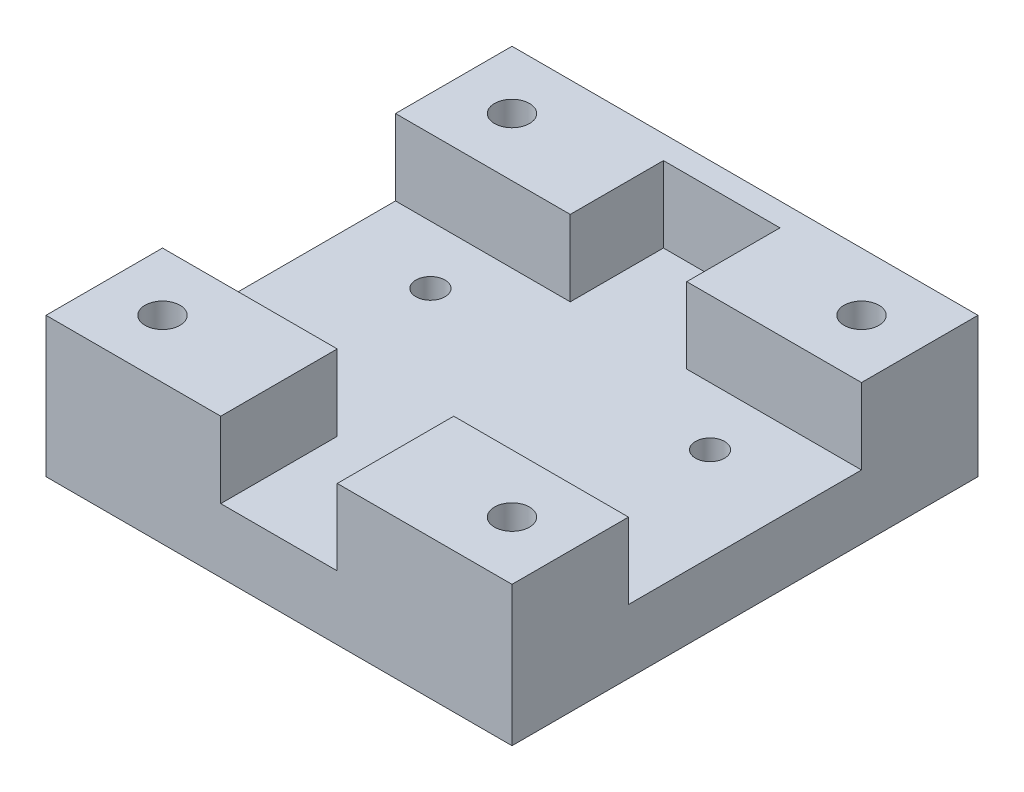
from build123d import *

# Parameters (mm, degrees)
BOSS_EXTRU_1_DEPTH      = 40
ENL_V_MAT_EXTRU_1_REACH = 14
ESQUISSE2_R             = 1.5
ESQUISSE2_R_2           = 1.25
ESQUISSE3_W             = 15
ESQUISSE3_H             = 20
ENL_V_MAT_EXTRU_2_DEPTH = 6.5
ESQUISSE4_W             = 40
ESQUISSE4_H             = 12
BOSS_EXTRU_2_DEPTH      = 2
CHANFREIN1_SIZE         = 2


with BuildPart() as part:
    # Esquisse1 → Boss.-Extru.1 (new body)
    with BuildSketch(Plane.XY):
        Polygon((5, 0), (20, 0), (20, -12), (-20, -12), (-20, 0), (-5, 0), (-5, -6.5), (5, -6.5), align=None)
    extrude(amount=BOSS_EXTRU_1_DEPTH)

    # Esquisse2 → Enlèv. mat.-Extru.1 (cut, up to next)
    with BuildSketch(Plane(origin=(0, 0, 0), x_dir=(1, 0, 0), z_dir=(0, 1, 0)), mode=Mode.PRIVATE) as enl_v_mat_extru_1_sk1:
        with Locations((-15, -5)):
            Circle(ESQUISSE2_R)
    enl_v_mat_extru_1_tool1 = extrude(enl_v_mat_extru_1_sk1.sketch, amount=-ENL_V_MAT_EXTRU_1_REACH, mode=Mode.PRIVATE) & part.part
    add(enl_v_mat_extru_1_tool1.solids().sort_by_distance((-15, 0, 5))[0], mode=Mode.SUBTRACT)
    # Esquisse2 → Enlèv. mat.-Extru.1 (cut, up to next)
    with BuildSketch(Plane(origin=(0, 0, 0), x_dir=(1, 0, 0), z_dir=(0, 1, 0)), mode=Mode.PRIVATE) as enl_v_mat_extru_1_sk2:
        with Locations((-15, -35)):
            Circle(ESQUISSE2_R)
    enl_v_mat_extru_1_tool2 = extrude(enl_v_mat_extru_1_sk2.sketch, amount=-ENL_V_MAT_EXTRU_1_REACH, mode=Mode.PRIVATE) & part.part
    add(enl_v_mat_extru_1_tool2.solids().sort_by_distance((-15, 0, 35))[0], mode=Mode.SUBTRACT)
    # Esquisse2 → Enlèv. mat.-Extru.1 (cut, up to next)
    with BuildSketch(Plane(origin=(0, 0, 0), x_dir=(1, 0, 0), z_dir=(0, 1, 0)), mode=Mode.PRIVATE) as enl_v_mat_extru_1_sk3:
        with Locations((15, -35)):
            Circle(ESQUISSE2_R)
    enl_v_mat_extru_1_tool3 = extrude(enl_v_mat_extru_1_sk3.sketch, amount=-ENL_V_MAT_EXTRU_1_REACH, mode=Mode.PRIVATE) & part.part
    add(enl_v_mat_extru_1_tool3.solids().sort_by_distance((15, 0, 35))[0], mode=Mode.SUBTRACT)
    # Esquisse2 → Enlèv. mat.-Extru.1 (cut, up to next)
    with BuildSketch(Plane(origin=(0, 0, 0), x_dir=(1, 0, 0), z_dir=(0, 1, 0)), mode=Mode.PRIVATE) as enl_v_mat_extru_1_sk4:
        with Locations((15, -5)):
            Circle(ESQUISSE2_R)
    enl_v_mat_extru_1_tool4 = extrude(enl_v_mat_extru_1_sk4.sketch, amount=-ENL_V_MAT_EXTRU_1_REACH, mode=Mode.PRIVATE) & part.part
    add(enl_v_mat_extru_1_tool4.solids().sort_by_distance((15, 0, 5))[0], mode=Mode.SUBTRACT)
    # Esquisse2 → Enlèv. mat.-Extru.1 (cut, up to next)
    with BuildSketch(Plane(origin=(0, 0, 0), x_dir=(1, 0, 0), z_dir=(0, 1, 0)), mode=Mode.PRIVATE) as enl_v_mat_extru_1_sk5:
        with Locations((-12, -25)):
            Circle(ESQUISSE2_R_2)
    enl_v_mat_extru_1_tool5 = extrude(enl_v_mat_extru_1_sk5.sketch, amount=-ENL_V_MAT_EXTRU_1_REACH, mode=Mode.PRIVATE) & part.part
    add(enl_v_mat_extru_1_tool5.solids().sort_by_distance((-12, 0, 25))[0], mode=Mode.SUBTRACT)
    # Esquisse2 → Enlèv. mat.-Extru.1 (cut, up to next)
    with BuildSketch(Plane(origin=(0, 0, 0), x_dir=(1, 0, 0), z_dir=(0, 1, 0)), mode=Mode.PRIVATE) as enl_v_mat_extru_1_sk6:
        with Locations((-12, -15)):
            Circle(ESQUISSE2_R_2)
    enl_v_mat_extru_1_tool6 = extrude(enl_v_mat_extru_1_sk6.sketch, amount=-ENL_V_MAT_EXTRU_1_REACH, mode=Mode.PRIVATE) & part.part
    add(enl_v_mat_extru_1_tool6.solids().sort_by_distance((-12, 0, 15))[0], mode=Mode.SUBTRACT)
    # Esquisse2 → Enlèv. mat.-Extru.1 (cut, up to next)
    with BuildSketch(Plane(origin=(0, 0, 0), x_dir=(1, 0, 0), z_dir=(0, 1, 0)), mode=Mode.PRIVATE) as enl_v_mat_extru_1_sk7:
        with Locations((12, -25)):
            Circle(ESQUISSE2_R_2)
    enl_v_mat_extru_1_tool7 = extrude(enl_v_mat_extru_1_sk7.sketch, amount=-ENL_V_MAT_EXTRU_1_REACH, mode=Mode.PRIVATE) & part.part
    add(enl_v_mat_extru_1_tool7.solids().sort_by_distance((12, 0, 25))[0], mode=Mode.SUBTRACT)
    # Esquisse2 → Enlèv. mat.-Extru.1 (cut, up to next)
    with BuildSketch(Plane(origin=(0, 0, 0), x_dir=(1, 0, 0), z_dir=(0, 1, 0)), mode=Mode.PRIVATE) as enl_v_mat_extru_1_sk8:
        with Locations((12, -15)):
            Circle(ESQUISSE2_R_2)
    enl_v_mat_extru_1_tool8 = extrude(enl_v_mat_extru_1_sk8.sketch, amount=-ENL_V_MAT_EXTRU_1_REACH, mode=Mode.PRIVATE) & part.part
    add(enl_v_mat_extru_1_tool8.solids().sort_by_distance((12, 0, 15))[0], mode=Mode.SUBTRACT)

    # Esquisse3 → Enlèv. mat.-Extru.2 (cut)
    with BuildSketch(Plane(origin=(0, 0, 0), x_dir=(1, 0, 0), z_dir=(0, 1, 0))):
        with Locations((-12.5, -20)):
            Rectangle(ESQUISSE3_W, ESQUISSE3_H)
        with Locations((12.5, -20)):
            Rectangle(ESQUISSE3_W, ESQUISSE3_H)
    extrude(amount=-ENL_V_MAT_EXTRU_2_DEPTH, mode=Mode.SUBTRACT)

    # Esquisse4 → Boss.-Extru.2 (add)
    with BuildSketch(Plane(origin=(0, 0, 0), x_dir=(-1, 0, 0), z_dir=(0, 0, -1))):
        with Locations((0, -6)):
            Rectangle(ESQUISSE4_W, ESQUISSE4_H)
    extrude(amount=-BOSS_EXTRU_2_DEPTH)

    # Chanfrein1
    chanfrein1_edges = [part.edges().sort_by_distance(p)[0] for p in [
        (-13.25, -12, 25),
        (-13.25, -12, 15),
        (10.75, -12, 25),
        (10.75, -12, 15),
    ]]
    chamfer(chanfrein1_edges, length=CHANFREIN1_SIZE)


solid = part.part
